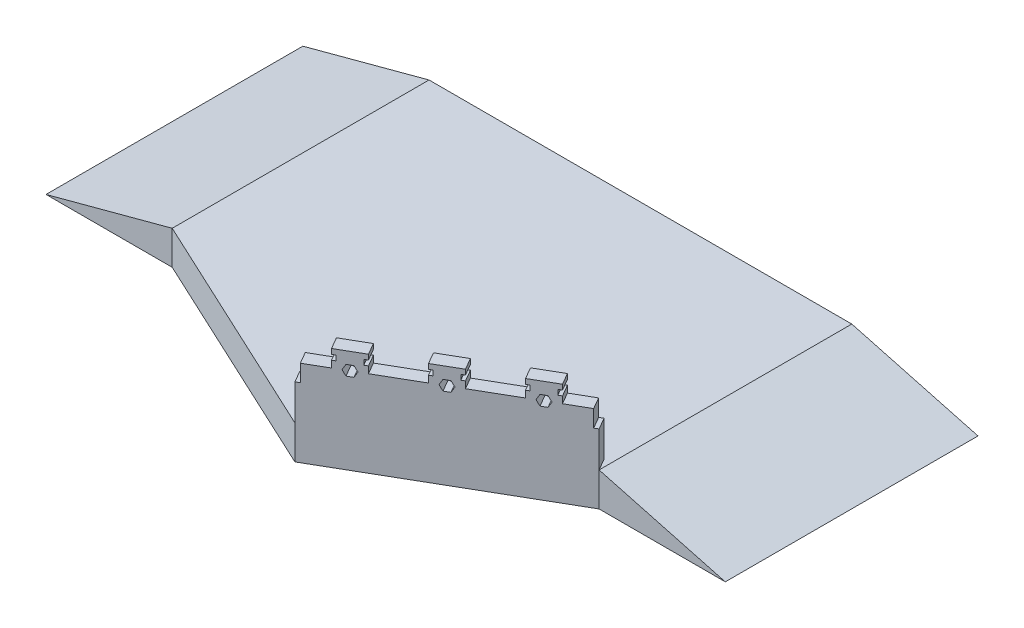
from build123d import *

# Parameters (mm, degrees)
EXTRUDE_1_DEPTH = 200
EXTRUDE_2_DEPTH = 1494.437287
EXTRUDE_3_DEPTH = 1519
SKETCH_5_W      = 1316.980211505
SKETCH_5_H      = 210
EXTRUDE_4_DEPTH = 80
EXTRUDE_6_DEPTH = 80


with BuildPart() as part:
    # 草图1 → 凸台-拉伸1 (new body)
    with BuildSketch(Plane(origin=(0, 0, 0), x_dir=(1, 0, 0), z_dir=(0, 1, 0))):
        Polygon((-1179.750139523, -120.638280303), (179.711541032, -754.565672914), (1320.249860477, -96.075567161), (1320.249860477, 1398.361719697), (-1179.750139523, 1398.361719697), align=None)
    extrude(amount=EXTRUDE_1_DEPTH)

    # 草图2 → 凸台-拉伸2 (add)
    with BuildSketch(Plane(origin=(0, 0, -1398.361719697), x_dir=(-1, 0, 0), z_dir=(0, 0, -1))):
        Polygon((-1320.249860477, 200), (-1320.249860477, 0), (-2066.660021991, 0), align=None)
    extrude(amount=-EXTRUDE_2_DEPTH)

    # 草图3 → 凸台-拉伸3 (add)
    with BuildSketch(Plane(origin=(0, 0, -1398.361719697), x_dir=(-1, 0, 0), z_dir=(0, 0, -1))):
        Polygon((1179.750139523, 200), (1179.750139523, 0), (1926.160301037, 0), align=None)
    extrude(amount=-EXTRUDE_3_DEPTH)

    # 草图5 → 凸台-拉伸4 (add)
    with BuildSketch(Plane(origin=(371.664406042, 0, 643.741634629), x_dir=(0.866025404, 0, -0.5), z_dir=(0.5, 0, 0.866025404))):
        with Locations((436.842029183, 305)):
            Rectangle(SKETCH_5_W, SKETCH_5_H)
    extrude(amount=-EXTRUDE_4_DEPTH)

    # 草图6 → 凸台-拉伸6 (add)
    with BuildSketch(Plane(origin=(371.664406042, 0, 643.741634629), x_dir=(0.866025404, 0, -0.5), z_dir=(0.5, 0, 0.866025404))):
        Polygon((-198.157970817, 410), (1071.842029183, 410), (1071.842029183, 510), (936.842029183, 510), (936.842029183, 550), (916.842029183, 550), (916.842029183, 580), (936.842029183, 580), (936.842029183, 610), (776.842029183, 610), (776.842029183, 580), (796.842029183, 580), (796.842029183, 550), (776.842029183, 550), (776.842029183, 510), (516.842029183, 510), (516.842029183, 550), (496.842029183, 550), (496.842029183, 580), (516.842029183, 580), (516.842029183, 610), (356.842029183, 610), (356.842029183, 580), (376.842029183, 580), (376.842029183, 550), (356.842029183, 550), (356.842029183, 510), (96.842029183, 510), (96.842029183, 550), (76.842029183, 550), (76.842029183, 580), (96.842029183, 580), (96.842029183, 610), (-63.157970817, 610), (-63.157970817, 580), (-43.157970817, 580), (-43.157970817, 550), (-63.157970817, 550), (-63.157970817, 510), (-198.157970817, 510), align=None)
        Polygon((471.483045334, 510), (454.162537258, 540), (419.521521107, 540), (402.201013031, 510), (419.521521107, 480), (454.162537258, 480), align=None, mode=Mode.SUBTRACT)
        Polygon((51.483045334, 510), (34.162537258, 540), (-0.478478893, 540), (-17.798986969, 510), (-0.478478893, 480), (34.162537258, 480), align=None, mode=Mode.SUBTRACT)
        Polygon((891.483045334, 510), (874.162537258, 540), (839.521521107, 540), (822.201013031, 510), (839.521521107, 480), (874.162537258, 480), align=None, mode=Mode.SUBTRACT)
    extrude(amount=-EXTRUDE_6_DEPTH)


solid = part.part
